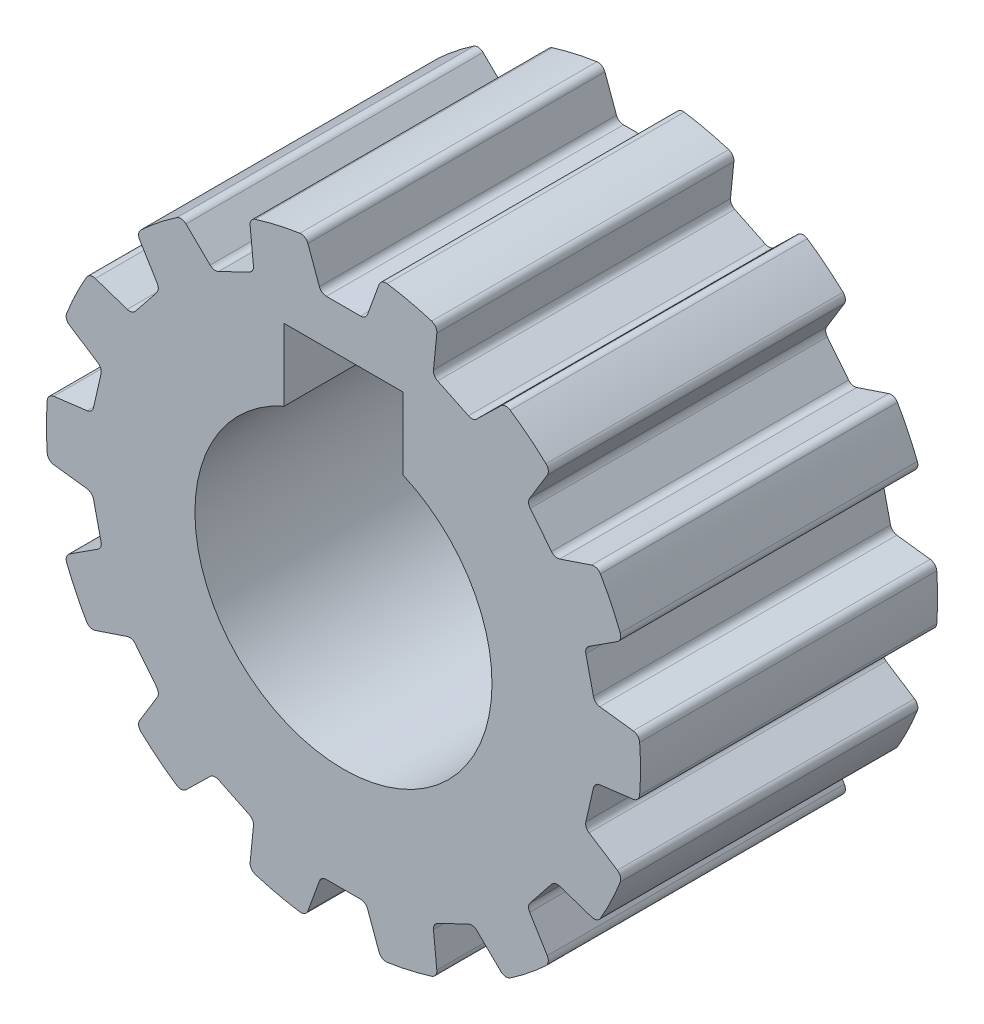
from build123d import *

# Parameters (mm, degrees)
SKETCH2_R           = 10
BOSS_EXTRUDE1_DEPTH = 10
CUT_EXTRUDE1_START  = -11
CUT_EXTRUDE1_DEPTH  = 12
CIRPATTERN1_COUNT   = 14
FILLET1_R           = 0.25


with BuildPart() as part:
    # Sketch2 → Boss-Extrude1 (new body)
    with BuildSketch(Plane.XY):
        Circle(SKETCH2_R)
        with BuildLine():
            Line((2, 4.582575695), (2, 7))
            Line((2, 7), (-2, 7))
            Line((-2, 7), (-2, 4.582575695))
            ThreePointArc((-2, 4.582575695), (0, -5), (2, 4.582575695))
        make_face(mode=Mode.SUBTRACT)
    extrude(amount=BOSS_EXTRUDE1_DEPTH)

    # Sketch3 → Cut-Extrude1 (cut)
    with BuildSketch(Plane.XY.offset(10).offset(CUT_EXTRUDE1_START)):
        Polygon((-20.341084154, 62.326061337), (-1.266640021, 9.919456792), (-0.75, 8.5), (0.75, 8.5), (1.266640021, 9.919456792), (20.341084154, 62.326061337), (20.341084154, 173.86594871), (-20.341084154, 173.86594871), align=None)
    cut_extrude1 = extrude(amount=CUT_EXTRUDE1_DEPTH, mode=Mode.SUBTRACT)

    # CirPattern1: Cut-Extrude1 ×14 about axis
    cirpattern1_axis = Axis((0, 0, 0), (0, 0, 1))
    for i in range(1, CIRPATTERN1_COUNT):
        add(cut_extrude1.rotate(cirpattern1_axis, i * 360 / CIRPATTERN1_COUNT), mode=Mode.SUBTRACT)

    # Fillet1
    fillet1_edges = [part.edges().sort_by_distance(p)[0] for p in [
        (7.113184952, 4.713289704, 5),
        (6.17795025, 5.886036928, 5),
        (8.453777954, 1.160232004, 5),
        (8.119996553, 2.622623873, 5),
        (8.119996553, -2.622623873, 5),
        (8.453777954, -1.160232004, 5),
        (6.17795025, -5.886036928, 5),
        (7.113184952, -4.713289704, 5),
        (3.012285132, -7.983648182, 5),
        (4.363738433, -7.332822573, 5),
        (-0.75, -8.5, 5),
        (0.75, -8.5, 5),
        (-4.363738433, -7.332822573, 5),
        (-3.012285132, -7.983648182, 5),
        (-7.113184952, -4.713289704, 5),
        (-6.17795025, -5.886036928, 5),
        (-8.453777954, -1.160232004, 5),
        (-8.119996553, -2.622623873, 5),
        (-8.119996553, 2.622623873, 5),
        (-8.453777954, 1.160232004, 5),
        (-6.17795025, 5.886036928, 5),
        (-7.113184952, 4.713289704, 5),
        (-3.012285132, 7.983648182, 5),
        (-4.363738433, 7.332822573, 5),
        (4.363738433, 7.332822573, 5),
        (3.012285132, 7.983648182, 5),
        (0.75, 8.5, 5),
        (-0.75, 8.5, 5),
        (-1.266640021, 9.919456792, 5),
        (1.266640021, 9.919456792, 5),
        (5.445094229, 8.387547248, 5),
        (3.162687777, 9.486696265, 5),
        (-3.162687777, 9.486696265, 5),
        (-5.445094229, 8.387547248, 5),
        (-6.965606473, 7.174979196, 5),
        (-8.545080745, 5.194381104, 5),
        (-9.38890138, 3.442169501, 5),
        (-9.952609221, 0.972404078, 5),
        (-9.952609221, -0.972404078, 5),
        (-9.38890138, -3.442169501, 5),
        (-8.545080745, -5.194381104, 5),
        (-6.965606473, -7.174979196, 5),
        (-5.445094229, -8.387547248, 5),
        (-3.162687777, -9.486696265, 5),
        (-1.266640021, -9.919456792, 5),
        (1.266640021, -9.919456792, 5),
        (3.162687777, -9.486696265, 5),
        (5.445094229, -8.387547248, 5),
        (6.965606473, -7.174979196, 5),
        (8.545080745, -5.194381104, 5),
        (9.38890138, -3.442169501, 5),
        (9.952609221, -0.972404078, 5),
        (9.952609221, 0.972404078, 5),
        (9.38890138, 3.442169501, 5),
        (8.545080745, 5.194381104, 5),
        (6.965606473, 7.174979196, 5),
    ]]
    fillet(fillet1_edges, radius=FILLET1_R)


solid = part.part
